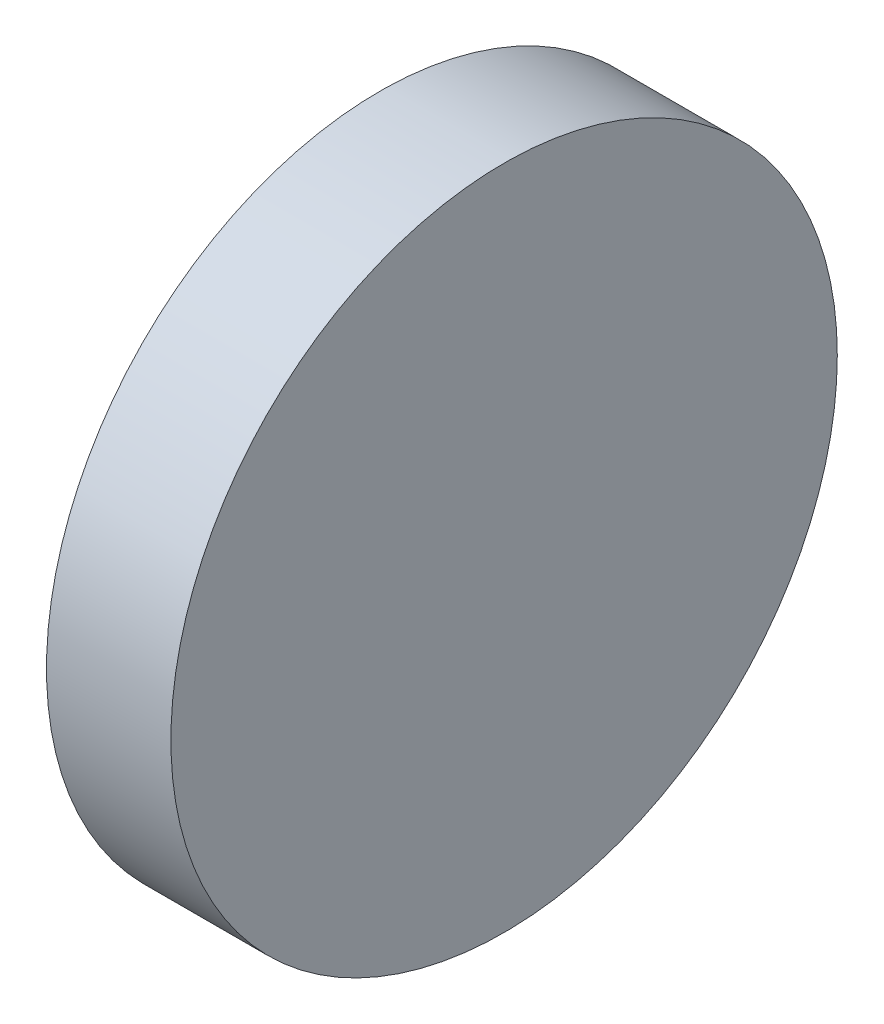
from build123d import *

# Parameters (mm, degrees)
SKETCH1_R           = 37.5
BOSS_EXTRUDE1_DEPTH = 7


with BuildPart() as part:
    # Sketch1 → Boss-Extrude1 (new body, symmetric)
    with BuildSketch(Plane(origin=(0, 0, 0), x_dir=(0, 0, -1), z_dir=(1, 0, 0))):
        Circle(SKETCH1_R)
    extrude(amount=BOSS_EXTRUDE1_DEPTH, both=True)


solid = part.part
